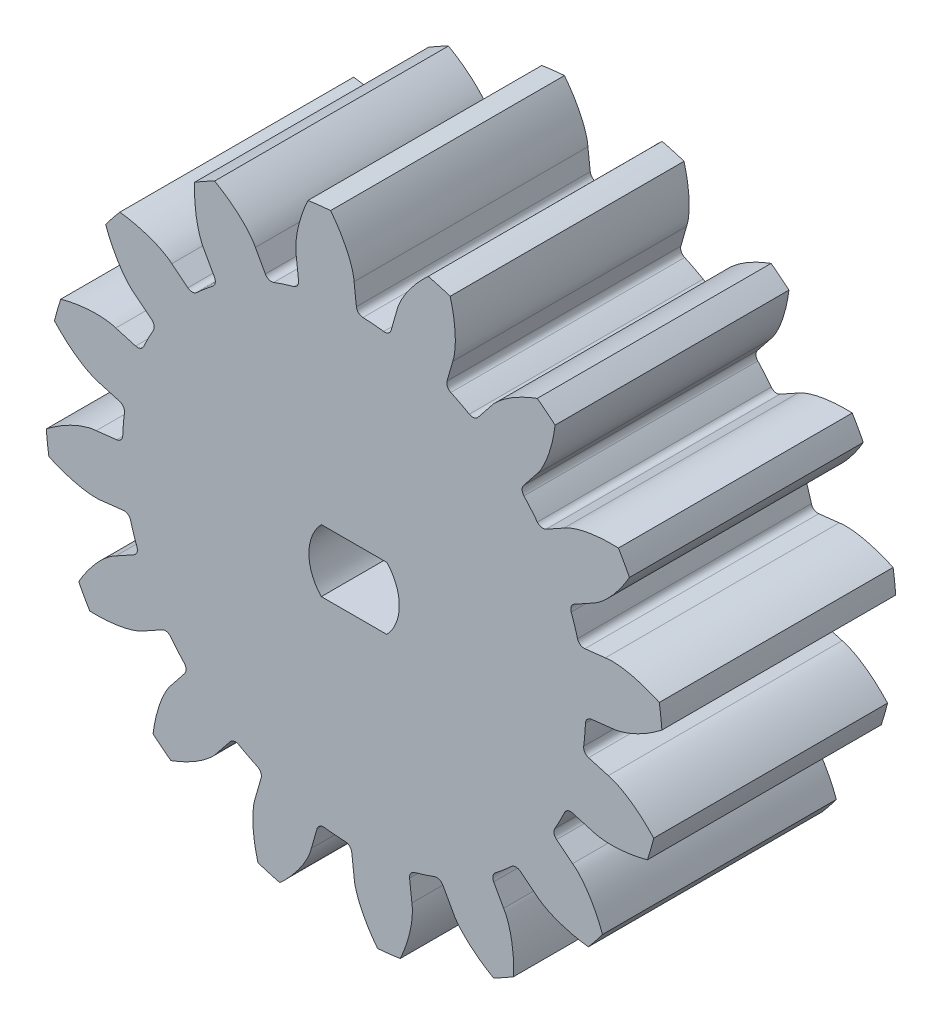
from build123d import *

# Parameters (mm, degrees)
SKETCH1_R                = 14.85
BOSS_EXTRUDE1_DEPTH      = 7.5
BOSS_EXTRUDE2_DEPTH      = 7.5
BOSS_EXTRUDE3_DEPTH      = 7.5
FILLET1_R                = 0.44
CIRPATTERN1_COUNT        = 16
FILLET1_OF_CIRPATTERN1_R = 0.44
CUT_EXTRUDE1_DEPTH       = 8
SKETCH8_R                = 3.25
CUT_EXTRUDE3_DEPTH       = 7


with BuildPart() as part:
    # Sketch1 → Boss-Extrude1 (new, symmetric)
    with BuildSketch(Plane.XY):
        Circle(SKETCH1_R)
    extrude(amount=BOSS_EXTRUDE1_DEPTH, both=True)

    # Sketch4 → Boss-Extrude2 (add, symmetric)
    with BuildSketch(Plane.XY):
        with BuildLine():
            Line((16.432971332, 1.866123403), (14.755164885, 1.675592195))
            ThreePointArc((14.755164885, 1.675592195), (14.826272265, 0.839136893), (14.85, 0))
            ThreePointArc((14.85, 0), (14.849690015, -0.095950305), (14.848760073, -0.191896605))
            Line((14.848760073, -0.191896605), (16.538590126, 0))
            ThreePointArc((16.538590126, 0), (16.512164315, 0.934554959), (16.432971332, 1.866123403))
        make_face()
        with BuildLine():
            ThreePointArc((14.427633903, 3.516515315), (14.620403064, 2.601213993), (14.755164885, 1.675592195))
            Line((14.755164885, 1.675592195), (16.432971332, 1.866123403))
            ThreePointArc((16.432971332, 1.866123403), (16.301264249, 2.791728361), (16.117463956, 3.70841192))
            Line((16.117463956, 3.70841192), (14.427633903, 3.516515315))
        make_face()
    boss_extrude2 = extrude(amount=BOSS_EXTRUDE2_DEPTH, both=True)

    # Sketch6 → Boss-Extrude3 (add, symmetric)
    with BuildSketch(Plane.XY):
        with BuildLine():
            ThreePointArc((16.117463956, 3.70841192), (16.432971332, 1.866123403), (16.538590126, 0))
            add(Edge.make_bspline(
                [(16.538590126, 0), (16.589565903, 0.002155289), (16.731955461, 0.015235028), (17.000222535, 0.066834111), (17.42693077, 0.188564705), (17.961772884, 0.400433789), (18.621652665, 0.733575704), (19.149356693, 1.067083669), (19.516944548, 1.331293876), (19.731290874, 1.496431414), (19.742700212, 1.505253581)],
                knots=[0, 0, 0, 0, 0, 0.005604071, 0.015718253, 0.029959921, 0.048733673, 0.068727069, 0.096888899, 0.098474473, 0.098474473, 0.098474473, 0.098474473, 0.098474473], degree=4))
            ThreePointArc((19.742700212, 1.505253581), (19.673553181, 2.234122927), (19.577506724, 2.959937582))
            add(Edge.make_bspline(
                [(16.117463956, 3.70841192), (16.167625001, 3.717741699), (16.3093217, 3.736922711), (16.582327773, 3.746790448), (17.025466017, 3.723839365), (17.594196257, 3.637291634), (18.311973041, 3.460595994), (18.901021774, 3.253906145), (19.318492927, 3.078847009), (19.564409729, 2.965976817), (19.577506724, 2.959937582)],
                knots=[0, 0, 0, 0, 0, 0.005604071, 0.015718253, 0.029959921, 0.048733673, 0.068727069, 0.096888899, 0.098474473, 0.098474473, 0.098474473, 0.098474473, 0.098474473], degree=4))
        make_face()
    boss_extrude3 = extrude(amount=BOSS_EXTRUDE3_DEPTH, both=True)

    # Fillet1
    fillet1_edges = [part.edges().sort_by_distance(p)[0] for p in [
        (14.427633903, 3.516515315, 0),
        (14.848760073, -0.191896605, 0),
    ]]
    fillet(fillet1_edges, radius=FILLET1_R)

    # CirPattern1: Boss-Extrude2, Boss-Extrude3 ×16 about axis
    cirpattern1_axis = Axis((0, 0, 7.5), (0, 0, -1))
    add([boss_extrude2.rotate(cirpattern1_axis, i * 360 / CIRPATTERN1_COUNT) for i in range(1, CIRPATTERN1_COUNT)])
    add([boss_extrude3.rotate(cirpattern1_axis, i * 360 / CIRPATTERN1_COUNT) for i in range(1, CIRPATTERN1_COUNT)])

    # Fillet1 of CirPattern1
    fillet1_of_cirpattern1_edges = [part.edges().sort_by_distance(p)[0] for p in [
        (14.675107816, -2.272379938, 0),
        (13.645029863, -5.859663817, 0),
        (12.688429595, -7.715325944, 0),
        (10.363967549, -10.63535033, 0),
        (8.770052988, -11.983683515, 0),
        (5.505085125, -13.791901166, 0),
        (3.516515315, -14.427633903, 0),
        (-0.191896605, -14.848760073, 0),
        (-2.272379938, -14.675107816, 0),
        (-5.859663817, -13.645029863, 0),
        (-7.715325944, -12.688429595, 0),
        (-10.63535033, -10.363967549, 0),
        (-11.983683515, -8.770052988, 0),
        (-13.791901166, -5.505085125, 0),
        (-14.427633903, -3.516515315, 0),
        (-14.848760073, 0.191896605, 0),
        (-14.675107816, 2.272379938, 0),
        (-13.645029863, 5.859663817, 0),
        (-12.688429595, 7.715325944, 0),
        (-10.363967549, 10.63535033, 0),
        (-8.770052988, 11.983683515, 0),
        (-5.505085125, 13.791901166, 0),
        (-3.516515315, 14.427633903, 0),
        (0.191896605, 14.848760073, 0),
        (2.272379938, 14.675107816, 0),
        (5.859663817, 13.645029863, 0),
        (7.715325944, 12.688429595, 0),
        (10.63535033, 10.363967549, 0),
        (11.983683515, 8.770052988, 0),
        (13.791901166, 5.505085125, 0),
    ]]
    fillet(fillet1_of_cirpattern1_edges, radius=FILLET1_OF_CIRPATTERN1_R)

    # Sketch7 → Cut-Extrude1 (cut)
    with BuildSketch(Plane.XY.offset(7.5)):
        with BuildLine():
            Line((2.1, 2), (-2.1, 2))
            ThreePointArc((-2.1, 2), (-2.9, 0), (-2.1, -2))
            Line((-2.1, -2), (2.1, -2))
            ThreePointArc((2.1, -2), (2.692582404, -1.077032961), (2.9, 0))
            ThreePointArc((2.9, 0), (2.692582404, 1.077032961), (2.1, 2))
        make_face()
    extrude(amount=-CUT_EXTRUDE1_DEPTH, mode=Mode.SUBTRACT)

    # Sketch8 → Cut-Extrude3 (cut)
    with BuildSketch(Plane(origin=(0, 0, -7.5), x_dir=(-1, 0, 0), z_dir=(0, 0, -1))):
        Circle(SKETCH8_R)
    extrude(amount=-CUT_EXTRUDE3_DEPTH, mode=Mode.SUBTRACT)


solid = part.part
